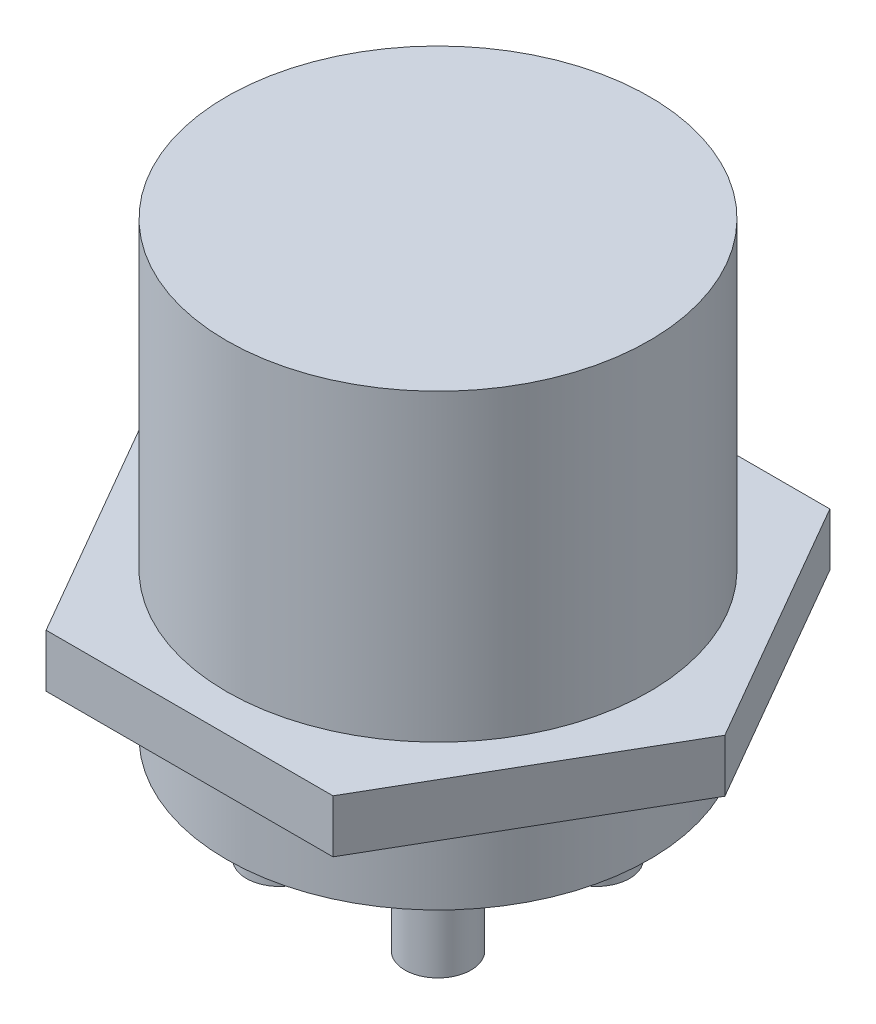
from build123d import *

# Parameters (mm, degrees)
SKETCH1_R             = 8
BOSS_EXTRUDE1_DEPTH   = 8.5
SKETCH2_R             = 1.25
BOSS_EXTRUDE2_DEPTH   = 4
BOSS_EXTRUDE2_2_DEPTH = 4
BOSS_EXTRUDE2_3_DEPTH = 4
BOSS_EXTRUDE2_4_DEPTH = 4
BOSS_EXTRUDE3_START   = -3
BOSS_EXTRUDE3_DEPTH   = 2


with BuildPart() as part:
    # Sketch1 → Boss-Extrude1 (new body, symmetric)
    with BuildSketch(Plane(origin=(0, 0, 0), x_dir=(1, 0, 0), z_dir=(0, 1, 0))):
        Circle(SKETCH1_R)
    extrude(amount=BOSS_EXTRUDE1_DEPTH, both=True)


with BuildPart() as body_2:
    # Sketch2 → Boss-Extrude2 (new body)
    with BuildSketch(Plane.XZ.offset(8.5)):
        with Locations((-3, 3)):
            Circle(SKETCH2_R)
    extrude(amount=BOSS_EXTRUDE2_DEPTH)


with BuildPart() as body_3:
    # Sketch2 → Boss-Extrude2 2 (new body)
    with BuildSketch(Plane.XZ.offset(8.5)):
        with Locations((3, 3)):
            Circle(SKETCH2_R)
    extrude(amount=BOSS_EXTRUDE2_2_DEPTH)


with BuildPart() as body_4:
    # Sketch2 → Boss-Extrude2 3 (new body)
    with BuildSketch(Plane.XZ.offset(8.5)):
        with Locations((3, -3)):
            Circle(SKETCH2_R)
    extrude(amount=BOSS_EXTRUDE2_3_DEPTH)


with BuildPart() as body_5:
    # Sketch2 → Boss-Extrude2 4 (new body)
    with BuildSketch(Plane.XZ.offset(8.5)):
        with Locations((-3, -3)):
            Circle(SKETCH2_R)
    extrude(amount=BOSS_EXTRUDE2_4_DEPTH)


with BuildPart() as body_6:
    # Sketch3 → Boss-Extrude3 (new body)
    with BuildSketch(Plane(origin=(0, 0, 0), x_dir=(1, 0, 0), z_dir=(0, 1, 0)).offset(BOSS_EXTRUDE3_START)):
        Polygon((10.854185061, 0), (5.42709253, 9.4), (-5.42709253, 9.4), (-10.854185061, 0), (-5.42709253, -9.4), (5.42709253, -9.4), align=None)
    extrude(amount=-BOSS_EXTRUDE3_DEPTH)


solid = Compound([part.part, body_2.part, body_3.part, body_4.part, body_5.part, body_6.part])
